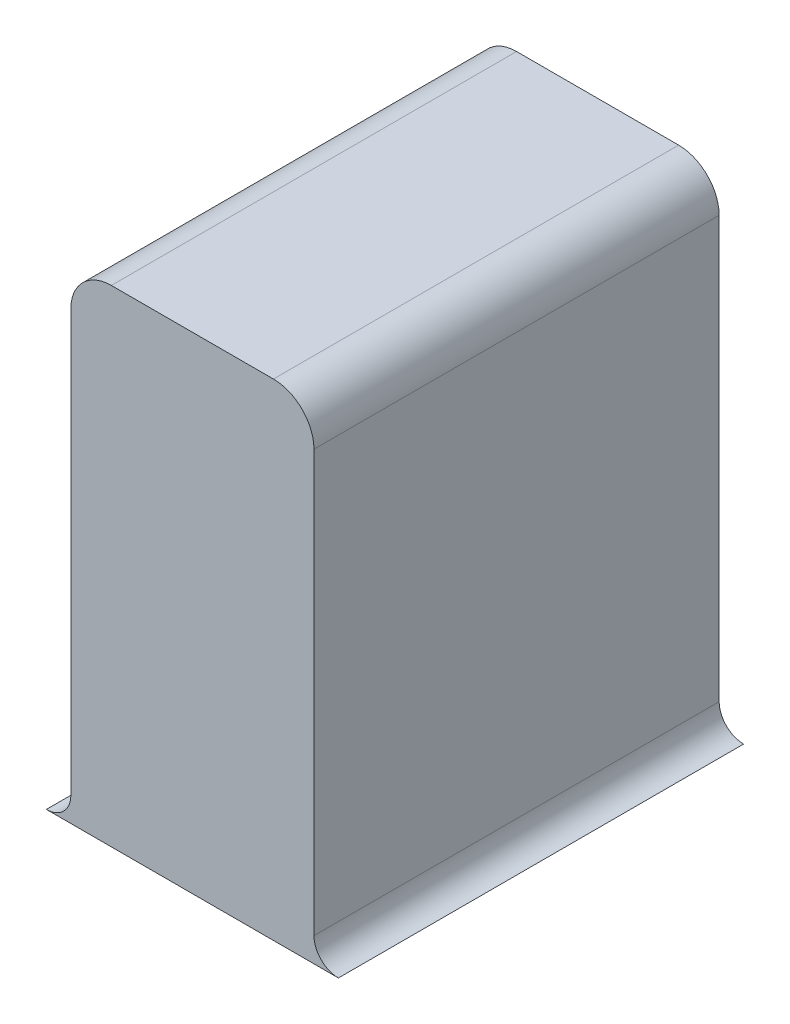
from build123d import *

# Parameters (mm, degrees)
ESBO_O1_W                = 1.5
ESBO_O1_H                = 6
RESSALTO_EXTRUS_O1_DEPTH = 5
FILETE1_R                = 0.5
RESSALTO_EXTRUS_O2_DEPTH = 5


with BuildPart() as part:
    # Esboço1 → Ressalto-extrusão1 (new body)
    with BuildSketch(Plane.XY):
        with Locations((-3.25, -34.87037037)):
            Rectangle(ESBO_O1_W, ESBO_O1_H)
        with Locations((-1.75, -34.87037037)):
            Rectangle(ESBO_O1_W, ESBO_O1_H)
    extrude(amount=RESSALTO_EXTRUS_O1_DEPTH)

    # Filete1
    filete1_edges = [part.edges().sort_by_distance(p)[0] for p in [
        (-1, -31.87037037, 2.5),
        (-4, -31.87037037, 2.5),
    ]]
    fillet(filete1_edges, radius=FILETE1_R)

    # Esboço1<5> → Ressalto-extrusão2 (add, through all)
    with BuildSketch(Plane.XY):
        with BuildLine():
            Line((-4.301867323, -37.87037037), (-4, -37.87037037))
            Line((-4, -37.87037037), (-4, -37.568503047))
            ThreePointArc((-4, -37.568503047), (-4.088414892, -37.781955478), (-4.301867323, -37.87037037))
        make_face()
        with BuildLine():
            Line((-1, -37.568503047), (-1, -37.87037037))
            Line((-1, -37.87037037), (-0.698132677, -37.87037037))
            ThreePointArc((-0.698132677, -37.87037037), (-0.911585108, -37.781955478), (-1, -37.568503047))
        make_face()
    extrude(amount=RESSALTO_EXTRUS_O2_DEPTH)


solid = part.part
